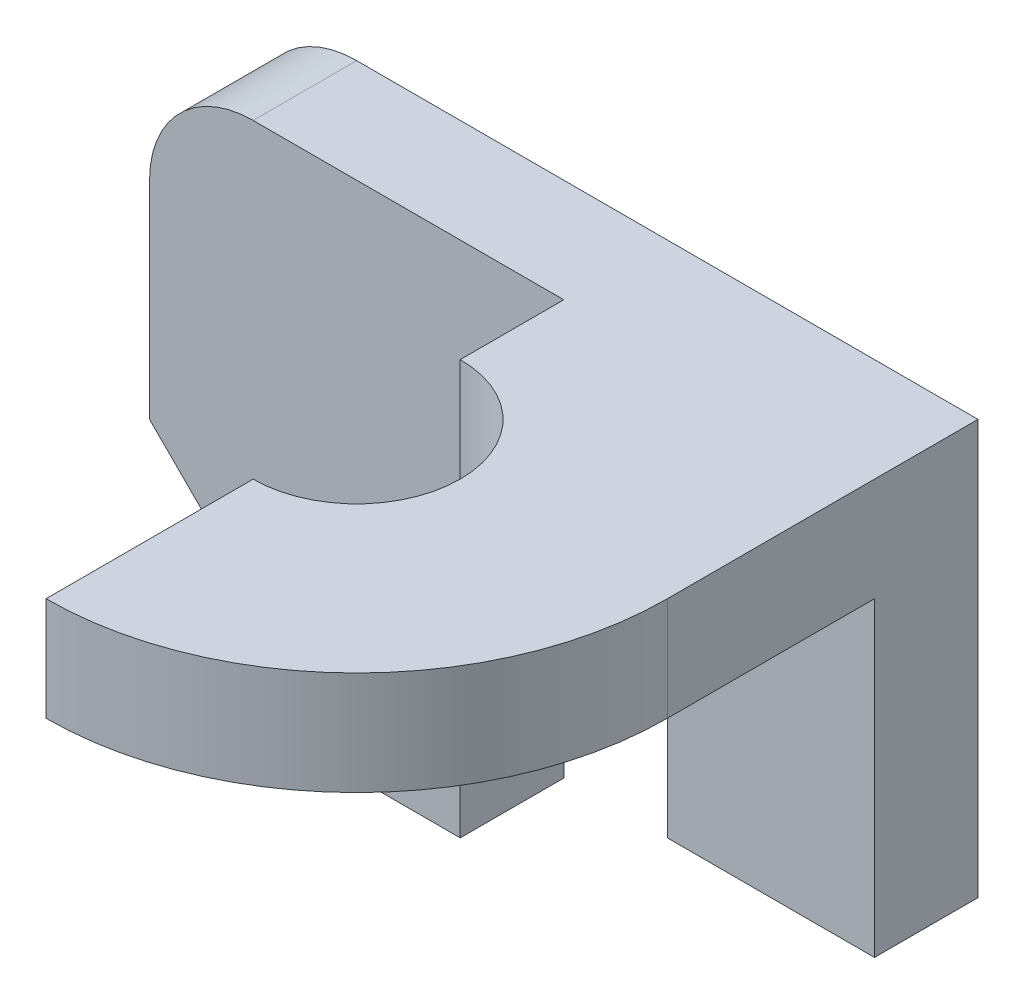
from build123d import *

# Parameters (mm, degrees)
BOSS_EXTRUDE1_DEPTH = 1
BOSS_EXTRUDE2_DEPTH = 1


with BuildPart() as part:
    # Sketch1 → Boss-Extrude1 (new body)
    with BuildSketch(Plane.XY):
        with BuildLine():
            Line((0, 0), (2, 0))
            Line((2, 0), (2, 4))
            Line((2, 4), (-4, 4))
            ThreePointArc((-4, 4), (-4.707106781, 3.707106781), (-5, 3))
            Line((-5, 3), (-5, 1))
            Line((-5, 1), (-3, -1))
            Line((-3, -1), (-2, -1))
            Line((-2, -1), (-2, 1))
            ThreePointArc((-2, 1), (-1, 2), (0, 1))
            Line((0, 1), (0, 0))
        make_face()
    extrude(amount=BOSS_EXTRUDE1_DEPTH)

    # Sketch2 → Boss-Extrude2 (add)
    with BuildSketch(Plane(origin=(0, 4, 0), x_dir=(1, 0, 0), z_dir=(0, 1, 0))):
        with BuildLine():
            Line((-1, -1), (2, -1))
            Line((2, -1), (2, -3))
            ThreePointArc((2, -3), (1.121320344, -5.121320344), (-1, -6))
            Line((-1, -6), (-1, -4))
            ThreePointArc((-1, -4), (0, -3), (-1, -2))
            Line((-1, -2), (-1, -1))
        make_face()
    extrude(amount=-BOSS_EXTRUDE2_DEPTH)


solid = part.part
